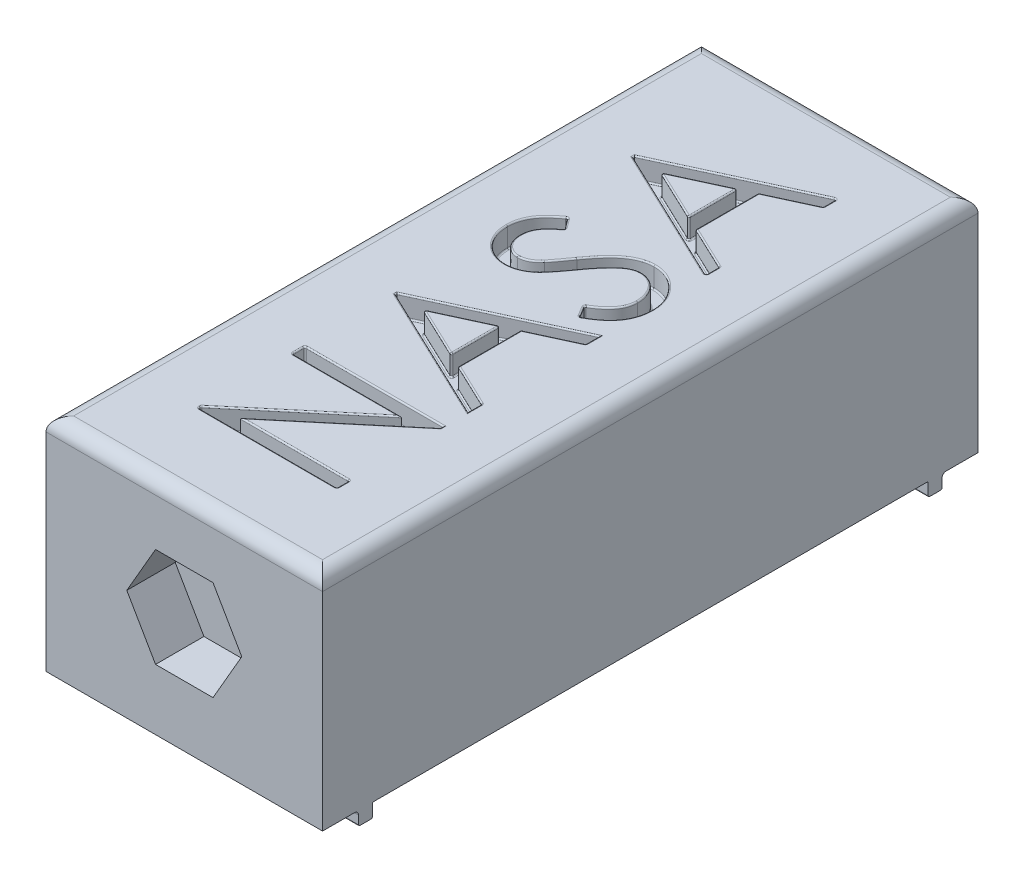
from build123d import *

# Parameters (mm, degrees)
SKETCH1_W           = 20
SKETCH1_H           = 40
BOSS_EXTRUDE1_DEPTH = 16
SKETCH2_W           = 20
SKETCH2_H           = 3.7
BOSS_EXTRUDE2_DEPTH = 16
CUT_EXTRUDE8_DEPTH  = 3.5
FILLET1_R           = 1
SKETCH4_W           = 20
SKETCH4_H           = 1
BOSS_EXTRUDE3_DEPTH = 1
FILLET2_R           = 0.3
FILLET3_R           = 0.1
CUT_EXTRUDE7_DEPTH  = 1.5
FILLET5_R           = 0.1


with BuildPart() as part:
    # Sketch1 → Boss-Extrude1 (new body)
    with BuildSketch(Plane(origin=(0, 0, 0), x_dir=(1, 0, 0), z_dir=(0, 1, 0))):
        Rectangle(SKETCH1_W, SKETCH1_H)
    extrude(amount=BOSS_EXTRUDE1_DEPTH)

    # Sketch2 → Boss-Extrude2 (add)
    with BuildSketch(Plane.XZ):
        with Locations((0, 21.85)):
            Rectangle(SKETCH2_W, SKETCH2_H)
        with Locations((0, -21.85)):
            Rectangle(SKETCH2_W, SKETCH2_H)
    extrude(amount=-BOSS_EXTRUDE2_DEPTH)

    # Sketch3 → Cut-Extrude8 (cut)
    with BuildSketch(Plane(origin=(0, 0, -23.7), x_dir=(-1, 0, 0), z_dir=(0, 0, -1))):
        Polygon((2.078460969, 11.6), (-2.078460969, 11.6), (-4.156921938, 8), (-2.078460969, 4.4), (2.078460969, 4.4), (4.156921938, 8), align=None)
    cut_extrude8 = extrude(amount=-CUT_EXTRUDE8_DEPTH, mode=Mode.SUBTRACT)

    # Fillet1
    fillet1_edges = [part.edges().sort_by_distance(p)[0] for p in [
        (10, 16, 0),
        (0, 16, 23.7),
        (0, 16, -23.7),
        (-10, 16, 0),
    ]]
    fillet(fillet1_edges, radius=FILLET1_R)

    # Sketch4 → Boss-Extrude3 (add)
    with BuildSketch(Plane.XZ):
        with Locations((0, -20.6)):
            Rectangle(SKETCH4_W, SKETCH4_H)
        with Locations((0, 20.6)):
            Rectangle(SKETCH4_W, SKETCH4_H)
    extrude(amount=BOSS_EXTRUDE3_DEPTH)

    # Fillet2
    fillet2_edges = [part.edges().sort_by_distance(p)[0] for p in [
        (0, 0, 21.1),
        (0, 0, -21.1),
    ]]
    fillet(fillet2_edges, radius=FILLET2_R)

    # Fillet3
    fillet3_edges = [part.edges().sort_by_distance(p)[0] for p in [
        (0, 0, 20.1),
        (0, -1, 20.1),
        (0, -1, 21.1),
        (0, 0, -20.1),
        (0, -1, -21.1),
        (0, -1, -20.1),
    ]]
    fillet(fillet3_edges, radius=FILLET3_R)

    # Sketch5 → Cut-Extrude7 (cut)
    with BuildSketch(Plane(origin=(0, 16, 0), x_dir=(1, 0, 0), z_dir=(0, 1, 0))):
        Polygon((-5, 13.871794872), (5, 18.487179487), (5, 17.51161859), (1.794871795, 16.033253205), (1.794871795, 11.5), (5, 9.979567308), (5, 9), (-5, 13.743589744), align=None)
        Polygon((-3.05088141, 13.797676282), (0.769230769, 11.986778846), (0.769230769, 15.560496795), align=None, mode=Mode.SUBTRACT)
        with BuildLine():
            Line((3.070913462, 1.820512821), (2.564102564, 2.665865385))
            add(Edge.make_bspline(
                [(2.564102564, 2.665865385), (2.818229762, 2.812251938), (3.174608999, 3.043435178), (3.578181578, 3.406850771), (3.815076147, 3.678183023), (4.001244681, 3.958960246), (4.176790885, 4.344659411), (4.231310594, 4.655668989), (4.230769231, 4.861378205)],
                knots=[0, 0, 0, 0, 0.3046461, 0.438546905, 0.562322299, 0.677432543, 0.786897393, 1, 1, 1, 1], degree=3))
            add(Edge.make_bspline(
                [(4.230769231, 4.861378205), (4.231469253, 5.035024898), (4.203462921, 5.295136323), (4.10275629, 5.62687476), (4.001522843, 5.863492857), (3.876909945, 6.08275427), (3.730011486, 6.278110079), (3.560265757, 6.443058776), (3.37396837, 6.579834751), (3.174208188, 6.68555861), (2.900091122, 6.792491737), (2.680186117, 6.817963174), (2.536057692, 6.820512821)],
                knots=[0, 0, 0, 0, 0.180992327, 0.270378773, 0.360477559, 0.448694185, 0.532623346, 0.614315552, 0.694490847, 0.772638072, 0.84928353, 1, 1, 1, 1], degree=3))
            add(Edge.make_bspline(
                [(2.536057692, 6.820512821), (2.367002633, 6.822260523), (2.014520587, 6.751298339), (1.703617477, 6.57227051), (1.554487179, 6.461939103)],
                knots=[0, 0, 0, 0, 0.475390581, 1, 1, 1, 1], degree=3))
            add(Edge.make_bspline(
                [(1.554487179, 6.461939103), (1.432807491, 6.369869965), (1.248807966, 6.213627198), (1.013249598, 5.972650866), (0.818272763, 5.759425822), (0.614909549, 5.521270546), (0.319834039, 5.157577447), (0.10641924, 4.862903526), (-0.040064103, 4.659054487)],
                knots=[0, 0, 0, 0, 0.189534325, 0.299204829, 0.41837415, 0.548365785, 0.688129118, 1, 1, 1, 1], degree=3))
            add(Edge.make_bspline(
                [(-0.040064103, 4.659054487), (-0.18167523, 4.456699865), (-0.391805799, 4.173483962), (-0.665354884, 3.819839279), (-0.843327938, 3.599120902), (-1.005015306, 3.409468893), (-1.181444981, 3.212344538), (-1.314969264, 3.089443741), (-1.400240385, 3.020432692)],
                knots=[0, 0, 0, 0, 0.347081672, 0.495567816, 0.628357302, 0.74551967, 0.845830751, 1, 1, 1, 1], degree=3))
            add(Edge.make_bspline(
                [(-1.400240385, 3.020432692), (-1.514761424, 2.932121683), (-1.690379005, 2.808530774), (-1.940585327, 2.677601094), (-2.12997399, 2.599595334), (-2.322566445, 2.536632334), (-2.585742717, 2.477775625), (-2.787805533, 2.460877274), (-2.922676282, 2.461538462)],
                knots=[0, 0, 0, 0, 0.262550464, 0.388251856, 0.511530984, 0.633734148, 0.755401792, 1, 1, 1, 1], degree=3))
            add(Edge.make_bspline(
                [(-2.922676282, 2.461538462), (-3.131933133, 2.461023784), (-3.4432143, 2.50051012), (-3.835586589, 2.63366106), (-4.110772618, 2.771519705), (-4.362260964, 2.949314872), (-4.592316175, 3.155901236), (-4.788346497, 3.399694951), (-4.956992923, 3.669590581), (-5.090209682, 3.963453118), (-5.220646299, 4.379101599), (-5.254452714, 4.706898185), (-5.256410256, 4.925480769)],
                knots=[0, 0, 0, 0, 0.165750923, 0.246236977, 0.327403713, 0.408725528, 0.489629677, 0.571609868, 0.655742455, 0.741223679, 0.826577067, 1, 1, 1, 1], degree=3))
            add(Edge.make_bspline(
                [(-5.256410256, 4.925480769), (-5.257611463, 5.159816353), (-5.212149035, 5.510204075), (-5.0601431, 5.954706576), (-4.927650608, 6.221206373), (-4.795962753, 6.430224661), (-4.675784035, 6.589468211), (-4.537705914, 6.751712592), (-4.37883552, 6.915226003), (-4.202312378, 7.081573673), (-3.933748626, 7.313177139), (-3.717141535, 7.480903339), (-3.563701923, 7.58974359)],
                knots=[0, 0, 0, 0, 0.213204388, 0.318561518, 0.426500592, 0.483340369, 0.543284906, 0.607974344, 0.677198563, 0.75074108, 0.82875151, 1, 1, 1, 1], degree=3))
            Line((-3.563701923, 7.58974359), (-2.948717949, 6.778445513))
            add(Edge.make_bspline(
                [(-2.948717949, 6.778445513), (-3.071418392, 6.685533761), (-3.243215968, 6.544296218), (-3.459156099, 6.356999635), (-3.594004505, 6.223160101), (-3.718116583, 6.10058443), (-3.822496697, 5.979510807), (-3.910430533, 5.864603885), (-4.004461135, 5.720110923), (-4.094741781, 5.537078382), (-4.201795178, 5.231287861), (-4.229574571, 4.987645196), (-4.230769231, 4.825320513)],
                knots=[0, 0, 0, 0, 0.18959042, 0.27412816, 0.352111321, 0.423687273, 0.489026015, 0.548936192, 0.601892205, 0.701259033, 0.799632682, 1, 1, 1, 1], degree=3))
            add(Edge.make_bspline(
                [(-4.230769231, 4.825320513), (-4.234472615, 4.626179409), (-4.189608269, 4.335456331), (-4.035129943, 3.98502139), (-3.873931906, 3.765970895), (-3.681505197, 3.585355051), (-3.387934726, 3.4072511), (-3.132983568, 3.359387922), (-2.96474359, 3.358974359)],
                knots=[0, 0, 0, 0, 0.275822022, 0.401868693, 0.527874505, 0.650458955, 0.765963766, 1, 1, 1, 1], degree=3))
            add(Edge.make_bspline(
                [(-2.96474359, 3.358974359), (-2.856566241, 3.356152361), (-2.696453438, 3.379091803), (-2.486920529, 3.434515625), (-2.330522815, 3.497736304), (-2.172006597, 3.58598737), (-1.941482861, 3.749530651), (-1.781115264, 3.905516922), (-1.672676282, 4.018028846)],
                knots=[0, 0, 0, 0, 0.216059268, 0.322956381, 0.434131058, 0.553424066, 0.686081248, 1, 1, 1, 1], degree=3))
            add(Edge.make_bspline(
                [(-1.672676282, 4.018028846), (-1.625576672, 4.069423178), (-1.548209168, 4.163408117), (-1.437060513, 4.312572794), (-1.321057774, 4.465287785), (-1.186560701, 4.648069131), (-0.971032877, 4.950961423), (-0.797433295, 5.191064767), (-0.677083333, 5.362179487)],
                knots=[0, 0, 0, 0, 0.124951974, 0.218093899, 0.333502411, 0.468789179, 0.624937586, 1, 1, 1, 1], degree=3))
            add(Edge.make_bspline(
                [(-0.677083333, 5.362179487), (-0.524642158, 5.572604094), (-0.301135926, 5.876543152), (0.009292041, 6.251006761), (0.227497252, 6.495203899), (0.437608333, 6.714810547), (0.641977978, 6.907624922), (0.839269453, 7.0745027), (1.090487138, 7.25666759), (1.401893384, 7.440256715), (1.900861258, 7.647884581), (2.292665401, 7.718005655), (2.550080128, 7.717948718)],
                knots=[0, 0, 0, 0, 0.187763162, 0.272381231, 0.35130177, 0.424311551, 0.491881862, 0.554202887, 0.610843189, 0.715917624, 0.814550236, 1, 1, 1, 1], degree=3))
            add(Edge.make_bspline(
                [(2.550080128, 7.717948718), (2.727821031, 7.720694271), (2.990976635, 7.691758934), (3.331213168, 7.606795038), (3.573453673, 7.513137583), (3.808633534, 7.396763599), (4.032328252, 7.251267195), (4.248882084, 7.081722261), (4.452224554, 6.887337672), (4.639121821, 6.674744132), (4.804690837, 6.449238852), (4.945914185, 6.213175848), (5.058415027, 5.963997799), (5.146882429, 5.704385255), (5.233814613, 5.338379534), (5.257164624, 5.053260409), (5.256410256, 4.861378205)],
                knots=[0, 0, 0, 0, 0.121796172, 0.180951717, 0.240298819, 0.299757378, 0.360799729, 0.423165447, 0.488345809, 0.553642156, 0.617280622, 0.680181591, 0.742141564, 0.804628492, 0.868235573, 1, 1, 1, 1], degree=3))
            add(Edge.make_bspline(
                [(5.256410256, 4.861378205), (5.257309137, 4.711143583), (5.239155382, 4.488246677), (5.190019951, 4.196174013), (5.132456069, 3.985844909), (5.062501454, 3.780024561), (4.976397893, 3.579603134), (4.87320255, 3.384488062), (4.755224288, 3.193572318), (4.617888654, 3.007392887), (4.458074755, 2.827493441), (4.279856255, 2.649144116), (4.080485528, 2.473598948), (3.857747982, 2.304732586), (3.525264351, 2.076740548), (3.257041946, 1.921203879), (3.070913462, 1.820512821)],
                knots=[0, 0, 0, 0, 0.113693769, 0.169174509, 0.224154701, 0.278714264, 0.333787494, 0.389233619, 0.445813093, 0.503694135, 0.564282525, 0.627962766, 0.694643383, 0.765377452, 0.839614674, 1, 1, 1, 1], degree=3))
        make_face()
        Polygon((-5, -3.307692308), (5, 1.307692308), (5, 0.33213141), (1.794871795, -1.146233974), (1.794871795, -5.679487179), (5, -7.199919872), (5, -8.179487179), (-5, -3.435897436), align=None)
        Polygon((-3.05088141, -3.381810897), (0.769230769, -5.192708333), (0.769230769, -1.618990385), align=None, mode=Mode.SUBTRACT)
        Polygon((5, -17.666666667), (-5, -17.666666667), (-5, -17.478365385), (2.870592949, -10.871794872), (-5, -10.871794872), (-5, -9.974358974), (5, -9.974358974), (5, -10.178685897), (-2.852564103, -16.769230769), (5, -16.769230769), align=None)
    extrude(amount=-CUT_EXTRUDE7_DEPTH, mode=Mode.SUBTRACT)

    # Fillet5
    fillet5_edges = [part.edges().sort_by_distance(p)[0] for p in [
        (-5, 16, -13.807692308),
        (0, 16, -16.179487179),
        (5, 16, -17.999399038),
        (5, 15.25, -18.487179487),
        (3.397435897, 16, -16.772435897),
        (5, 15.25, -17.51161859),
        (1.794871795, 16, -13.766626603),
        (1.794871795, 15.25, -16.033253205),
        (3.397435897, 16, -10.739783654),
        (1.794871795, 15.25, -11.5),
        (5, 16, -9.489783654),
        (5, 15.25, -9.979567308),
        (0, 16, -11.371794872),
        (5, 15.25, -9),
        (0.769230769, 14.5, -13.773637821),
        (-1.140825321, 14.5, -14.679086538),
        (-1.140825321, 14.5, -12.892227564),
        (-5, 14.5, -13.807692308),
        (0, 14.5, -16.179487179),
        (5, 14.5, -17.999399038),
        (3.397435897, 14.5, -16.772435897),
        (1.794871795, 14.5, -13.766626603),
        (3.397435897, 14.5, -10.739783654),
        (5, 14.5, -9.489783654),
        (0, 14.5, -11.371794872),
        (-1.140825321, 16, -14.679086538),
        (0.769230769, 15.25, -15.560496795),
        (0.769230769, 16, -13.773637821),
        (0.769230769, 15.25, -11.986778846),
        (-1.140825321, 16, -12.892227564),
        (-3.05088141, 15.25, -13.797676282),
        (3.700672727, 16, -3.550006114),
        (2.817508013, 16, -2.243189103),
        (3.070913462, 15.25, -1.820512821),
        (3.700672727, 16, -3.550006114),
        (2.564102564, 15.25, -2.665865385),
        (3.783939588, 16, -6.203494901),
        (2.016907138, 16, -6.721191628),
        (0.696224793, 16, -5.615866935),
        (-0.678969011, 16, -3.804252006),
        (-2.113571473, 16, -2.608410261),
        (-3.905224243, 16, -3.815397683),
        (-4.764273488, 16, -6.470353388),
        (-3.256209936, 16, -7.184094551),
        (-3.563701923, 15.25, -7.58974359),
        (-3.841040389, 16, -5.954052461),
        (-2.948717949, 15.25, -6.778445513),
        (-3.905224243, 16, -3.815397683),
        (-2.248320389, 16, -3.544484333),
        (-1.163341405, 16, -4.681354501),
        (0.696224793, 16, -5.615866935),
        (3.783939588, 16, -6.203494901),
        (3.700672727, 14.5, -3.550006114),
        (2.817508013, 14.5, -2.243189103),
        (3.700672727, 14.5, -3.550006114),
        (3.783939588, 14.5, -6.203494901),
        (2.016907138, 14.5, -6.721191628),
        (0.696224793, 14.5, -5.615866935),
        (-0.678969011, 14.5, -3.804252006),
        (-2.113571473, 14.5, -2.608410261),
        (-3.905224243, 14.5, -3.815397683),
        (-4.764273488, 14.5, -6.470353388),
        (-3.256209936, 14.5, -7.184094551),
        (-3.841040389, 14.5, -5.954052461),
        (-3.905224243, 14.5, -3.815397683),
        (-2.248320389, 14.5, -3.544484333),
        (-1.163341405, 14.5, -4.681354501),
        (0.696224793, 14.5, -5.615866935),
        (3.783939588, 14.5, -6.203494901),
        (-5, 16, 3.371794872),
        (0, 16, 1),
        (5, 16, -0.819911859),
        (3.397435897, 16, 0.407051282),
        (5, 15.25, -0.33213141),
        (1.794871795, 16, 3.412860577),
        (1.794871795, 15.25, 1.146233974),
        (3.397435897, 16, 6.439703526),
        (1.794871795, 15.25, 5.679487179),
        (5, 16, 7.689703526),
        (5, 15.25, 7.199919872),
        (0, 16, 5.807692308),
        (0.769230769, 14.5, 3.405849359),
        (-1.140825321, 14.5, 2.500400641),
        (-1.140825321, 14.5, 4.287259615),
        (-5, 14.5, 3.371794872),
        (0, 14.5, 1),
        (5, 14.5, -0.819911859),
        (3.397435897, 14.5, 0.407051282),
        (1.794871795, 14.5, 3.412860577),
        (3.397435897, 14.5, 6.439703526),
        (5, 14.5, 7.689703526),
        (0, 14.5, 5.807692308),
        (-1.140825321, 16, 2.500400641),
        (0.769230769, 15.25, 1.618990385),
        (0.769230769, 16, 3.405849359),
        (0.769230769, 15.25, 5.192708333),
        (-1.140825321, 16, 4.287259615),
        (-3.05088141, 15.25, 3.381810897),
        (5, 16, 17.217948718),
        (5, 15.25, 16.769230769),
        (0, 16, 17.666666667),
        (5, 15.25, 17.666666667),
        (-5, 16, 17.572516026),
        (-5, 15.25, 17.666666667),
        (-1.064703526, 16, 14.175080128),
        (-5, 15.25, 17.478365385),
        (-1.064703526, 16, 10.871794872),
        (-5, 16, 10.423076923),
        (-5, 15.25, 10.871794872),
        (0, 16, 9.974358974),
        (-5, 15.25, 9.974358974),
        (5, 16, 10.076522436),
        (1.073717949, 16, 13.473958333),
        (1.073717949, 16, 16.769230769),
        (5, 14.5, 17.217948718),
        (0, 14.5, 17.666666667),
        (-5, 14.5, 17.572516026),
        (-1.064703526, 14.5, 14.175080128),
        (-1.064703526, 14.5, 10.871794872),
        (-5, 14.5, 10.423076923),
        (0, 14.5, 9.974358974),
        (5, 14.5, 10.076522436),
        (1.073717949, 14.5, 13.473958333),
        (1.073717949, 14.5, 16.769230769),
    ]]
    fillet(fillet5_edges, radius=FILLET5_R)

    # Mirror1: Cut-Extrude8 across plane
    add(cut_extrude8.mirror(Plane.XY), mode=Mode.SUBTRACT)


solid = part.part
